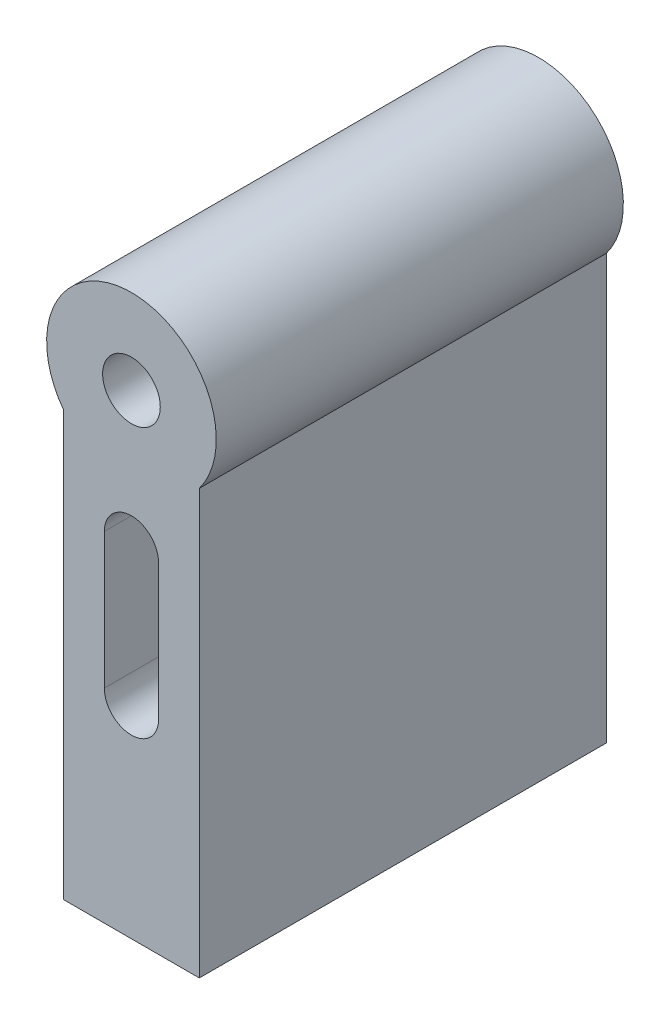
from build123d import *

# Parameters (mm, degrees)
CROQUIS1_R              = 1.7
SALIENTE_EXTRUIR1_DEPTH = 12
CROQUIS2_R              = 1.7
TORNILLO_DEPTH          = 10
TUERCA_DEPTH            = 4


with BuildPart() as part:
    # Croquis1 → Saliente-Extruir1 (new body, symmetric)
    with BuildSketch(Plane.XY):
        with BuildLine():
            Line((-4, -3), (-4, -28))
            Line((-4, -28), (4, -28))
            Line((4, -28), (4, -3))
            ThreePointArc((4, -3), (0, 5), (-4, -3))
        make_face()
        Circle(CROQUIS1_R, mode=Mode.SUBTRACT)
        with BuildLine():
            Line((1.6, -8), (1.6, -16))
            ThreePointArc((1.6, -16), (0, -17.6), (-1.6, -16))
            Line((-1.6, -16), (-1.6, -8))
            ThreePointArc((-1.6, -8), (0, -6.4), (1.6, -8))
        make_face(mode=Mode.SUBTRACT)
    extrude(amount=SALIENTE_EXTRUIR1_DEPTH, both=True)

    # Croquis2 → TORNILLO (cut)
    with BuildSketch(Plane.XZ.offset(28)):
        with Locations((0, -7)):
            Circle(CROQUIS2_R)
    tornillo = extrude(amount=-TORNILLO_DEPTH, mode=Mode.SUBTRACT)

    # Croquis3 → TUERCA (cut)
    with BuildSketch(Plane(origin=(0, -24.2, 0), x_dir=(-1, 0, 0), z_dir=(0, -1, 0))):
        Polygon((1.703183294, 9.95), (5, 9.95), (5, 4.05), (1.703183294, 4.05), (-1.703183294, 4.05), (-3.406366588, 7), (-1.703183294, 9.95), align=None)
    tuerca = extrude(amount=-TUERCA_DEPTH, mode=Mode.SUBTRACT)

    # Simetría1: TORNILLO, TUERCA across plane
    add(tornillo.mirror(Plane.XY), mode=Mode.SUBTRACT)
    add(tuerca.mirror(Plane.XY), mode=Mode.SUBTRACT)


solid = part.part
